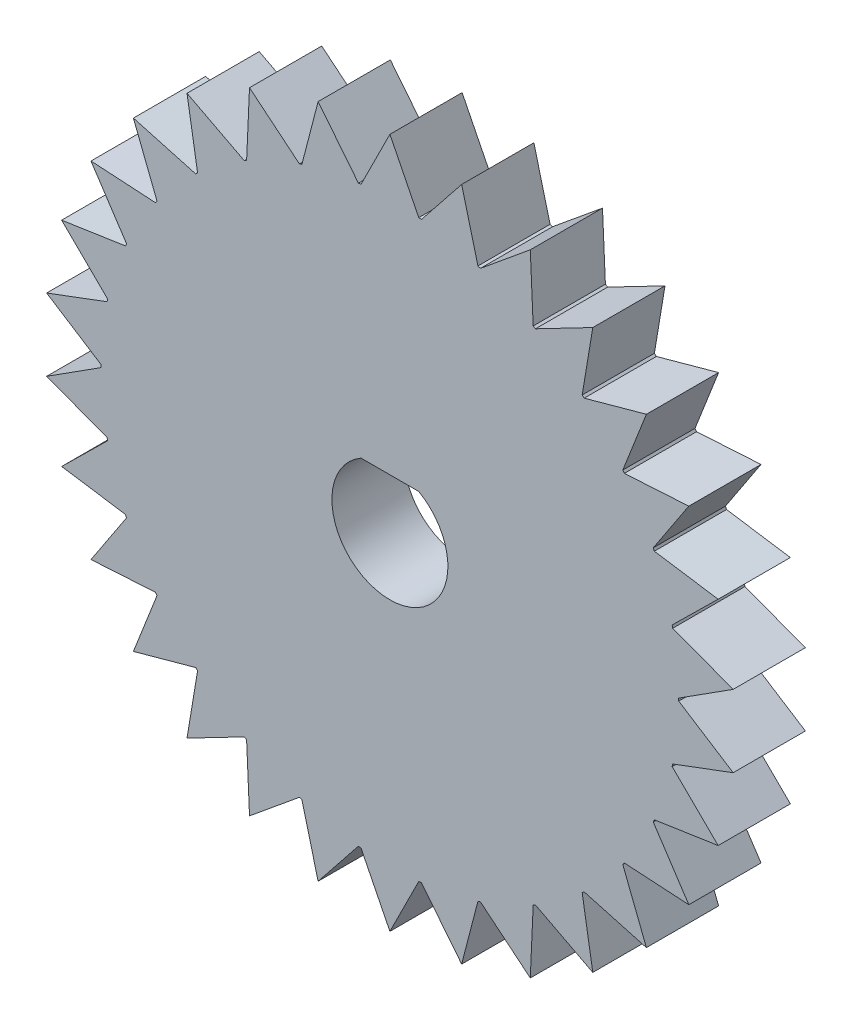
from build123d import *

# Parameters (mm, degrees)
BOSS_EXTRUDE1_DEPTH = 3.175
SKETCH2_R           = 2.55
CUT_EXTRUDE1_DEPTH  = 4.175
BOSS_EXTRUDE2_DEPTH = 3.175


with BuildPart() as part:
    # Sketch1 → Boss-Extrude1 (new body)
    with BuildSketch(Plane.XY):
        with BuildLine():
            Line((1.27, 12.636340451), (0, 15.176340451))
            Line((0, 15.176340451), (-1.27, 12.636340451))
            ThreePointArc((-1.27, 12.636340451), (-1.327511483, 12.630428071), (-1.384995456, 12.624253942))
            Line((-1.384995456, 12.624253942), (-3.155338604, 14.844701))
            Line((-3.155338604, 14.844701), (-3.869490362, 12.096158247))
            ThreePointArc((-3.869490362, 12.096158247), (-3.924515829, 12.078417757), (-3.979459965, 12.060426957))
            Line((-3.979459965, 12.060426957), (-6.172773769, 13.864276883))
            Line((-6.172773769, 13.864276883), (-6.299865427, 11.027315884))
            ThreePointArc((-6.299865427, 11.027315884), (-6.35, 10.998522628), (-6.400002977, 10.969501442))
            Line((-6.400002977, 10.969501442), (-8.920429101, 12.277917337))
            Line((-8.920429101, 12.277917337), (-8.454906143, 9.476526901))
            ThreePointArc((-8.454906143, 9.476526901), (-8.497958701, 9.437939284), (-8.540835149, 9.399156077))
            Line((-8.540835149, 9.399156077), (-11.278218876, 10.154953888))
            Line((-11.278218876, 10.154953888), (-10.240426889, 7.51156822))
            ThreePointArc((-10.240426889, 7.51156822), (-10.274515829, 7.464872704), (-10.308391842, 7.418022488))
            Line((-10.308391842, 7.418022488), (-13.143096367, 7.588170226))
            Line((-13.143096367, 7.588170226), (-11.578391842, 5.218317963))
            ThreePointArc((-11.578391842, 5.218317963), (-11.602027312, 5.165555367), (-11.625422345, 5.112685722))
            Line((-11.625422345, 5.112685722), (-14.43355748, 4.689747112))
            Line((-14.43355748, 4.689747112), (-12.410325511, 2.69700217))
            ThreePointArc((-12.410325511, 2.69700217), (-12.422474529, 2.640478473), (-12.434366108, 2.583900056))
            Line((-12.434366108, 2.583900056), (-15.09320287, 1.586359545))
            Line((-15.09320287, 1.586359545), (-12.699868404, 0.057814442))
            ThreePointArc((-12.699868404, 0.057814442), (-12.7, 0), (-12.699868404, -0.057814442))
            Line((-12.699868404, -0.057814442), (-15.09320287, -1.586359545))
            Line((-15.09320287, -1.586359545), (-12.434366108, -2.583900056))
            ThreePointArc((-12.434366108, -2.583900056), (-12.422474529, -2.640478473), (-12.410325511, -2.69700217))
            Line((-12.410325511, -2.69700217), (-14.43355748, -4.689747112))
            Line((-14.43355748, -4.689747112), (-11.625422345, -5.112685722))
            ThreePointArc((-11.625422345, -5.112685722), (-11.602027312, -5.165555367), (-11.578391842, -5.218317963))
            Line((-11.578391842, -5.218317963), (-13.143096367, -7.588170226))
            Line((-13.143096367, -7.588170226), (-10.308391842, -7.418022488))
            ThreePointArc((-10.308391842, -7.418022488), (-10.274515829, -7.464872704), (-10.240426889, -7.51156822))
            Line((-10.240426889, -7.51156822), (-11.278218876, -10.154953888))
            Line((-11.278218876, -10.154953888), (-8.540835149, -9.399156077))
            ThreePointArc((-8.540835149, -9.399156077), (-8.497958701, -9.437939284), (-8.454906143, -9.476526901))
            Line((-8.454906143, -9.476526901), (-8.920429101, -12.277917337))
            Line((-8.920429101, -12.277917337), (-6.400002977, -10.969501442))
            ThreePointArc((-6.400002977, -10.969501442), (-6.35, -10.998522628), (-6.299865427, -11.027315884))
            Line((-6.299865427, -11.027315884), (-6.172773769, -13.864276883))
            Line((-6.172773769, -13.864276883), (-3.979459965, -12.060426957))
            ThreePointArc((-3.979459965, -12.060426957), (-3.924515829, -12.078417757), (-3.869490362, -12.096158247))
            Line((-3.869490362, -12.096158247), (-3.155338604, -14.844701))
            Line((-3.155338604, -14.844701), (-1.384995456, -12.624253942))
            ThreePointArc((-1.384995456, -12.624253942), (-1.327511483, -12.630428071), (-1.27, -12.636340451))
            Line((-1.27, -12.636340451), (0, -15.176340451))
            Line((0, -15.176340451), (1.27, -12.636340451))
            ThreePointArc((1.27, -12.636340451), (1.327511483, -12.630428071), (1.384995456, -12.624253942))
            Line((1.384995456, -12.624253942), (3.155338604, -14.844701))
            Line((3.155338604, -14.844701), (3.869490362, -12.096158247))
            ThreePointArc((3.869490362, -12.096158247), (3.924515829, -12.078417757), (3.979459965, -12.060426957))
            Line((3.979459965, -12.060426957), (6.172773769, -13.864276883))
            Line((6.172773769, -13.864276883), (6.299865427, -11.027315884))
            ThreePointArc((6.299865427, -11.027315884), (6.35, -10.998522628), (6.400002977, -10.969501442))
            Line((6.400002977, -10.969501442), (8.920429101, -12.277917337))
            Line((8.920429101, -12.277917337), (8.454906143, -9.476526901))
            ThreePointArc((8.454906143, -9.476526901), (8.497958701, -9.437939284), (8.540835149, -9.399156077))
            Line((8.540835149, -9.399156077), (11.278218876, -10.154953888))
            Line((11.278218876, -10.154953888), (10.240426889, -7.51156822))
            ThreePointArc((10.240426889, -7.51156822), (10.274515829, -7.464872704), (10.308391842, -7.418022488))
            Line((10.308391842, -7.418022488), (13.143096367, -7.588170226))
            Line((13.143096367, -7.588170226), (11.578391842, -5.218317963))
            ThreePointArc((11.578391842, -5.218317963), (11.602027312, -5.165555367), (11.625422345, -5.112685722))
            Line((11.625422345, -5.112685722), (14.43355748, -4.689747112))
            Line((14.43355748, -4.689747112), (12.410325511, -2.69700217))
            ThreePointArc((12.410325511, -2.69700217), (12.422474529, -2.640478473), (12.434366108, -2.583900056))
            Line((12.434366108, -2.583900056), (15.09320287, -1.586359545))
            Line((15.09320287, -1.586359545), (12.699868404, -0.057814442))
            ThreePointArc((12.699868404, -0.057814442), (12.7, 0), (12.699868404, 0.057814442))
            Line((12.699868404, 0.057814442), (15.09320287, 1.586359545))
            Line((15.09320287, 1.586359545), (12.434366108, 2.583900056))
            ThreePointArc((12.434366108, 2.583900056), (12.422474529, 2.640478473), (12.410325511, 2.69700217))
            Line((12.410325511, 2.69700217), (14.43355748, 4.689747112))
            Line((14.43355748, 4.689747112), (11.625422345, 5.112685722))
            ThreePointArc((11.625422345, 5.112685722), (11.602027312, 5.165555367), (11.578391842, 5.218317963))
            Line((11.578391842, 5.218317963), (13.143096367, 7.588170226))
            Line((13.143096367, 7.588170226), (10.308391842, 7.418022488))
            ThreePointArc((10.308391842, 7.418022488), (10.274515829, 7.464872704), (10.240426889, 7.51156822))
            Line((10.240426889, 7.51156822), (11.278218876, 10.154953888))
            Line((11.278218876, 10.154953888), (8.540835149, 9.399156077))
            ThreePointArc((8.540835149, 9.399156077), (8.497958701, 9.437939284), (8.454906143, 9.476526901))
            Line((8.454906143, 9.476526901), (8.920429101, 12.277917337))
            Line((8.920429101, 12.277917337), (6.400002977, 10.969501442))
            ThreePointArc((6.400002977, 10.969501442), (6.35, 10.998522628), (6.299865427, 11.027315884))
            Line((6.299865427, 11.027315884), (6.172773769, 13.864276883))
            Line((6.172773769, 13.864276883), (3.979459965, 12.060426957))
            ThreePointArc((3.979459965, 12.060426957), (3.924515829, 12.078417757), (3.869490362, 12.096158247))
            Line((3.869490362, 12.096158247), (3.155338604, 14.844701))
            Line((3.155338604, 14.844701), (1.384995456, 12.624253942))
            ThreePointArc((1.384995456, 12.624253942), (1.327511483, 12.630428071), (1.27, 12.636340451))
        make_face()
    extrude(amount=BOSS_EXTRUDE1_DEPTH)

    # Sketch2 → Cut-Extrude1 (cut, through all)
    with BuildSketch(Plane.XY.offset(3.175)):
        Circle(SKETCH2_R)
    extrude(amount=-CUT_EXTRUDE1_DEPTH, mode=Mode.SUBTRACT)

    # Sketch3 → Boss-Extrude2 (add, through all)
    with BuildSketch(Plane.XY.offset(3.175)):
        with BuildLine():
            Line((-1.27, 2.211243994), (1.27, 2.211243994))
            ThreePointArc((1.27, 2.211243994), (0, 2.55), (-1.27, 2.211243994))
        make_face()
    extrude(amount=-BOSS_EXTRUDE2_DEPTH)


solid = part.part
